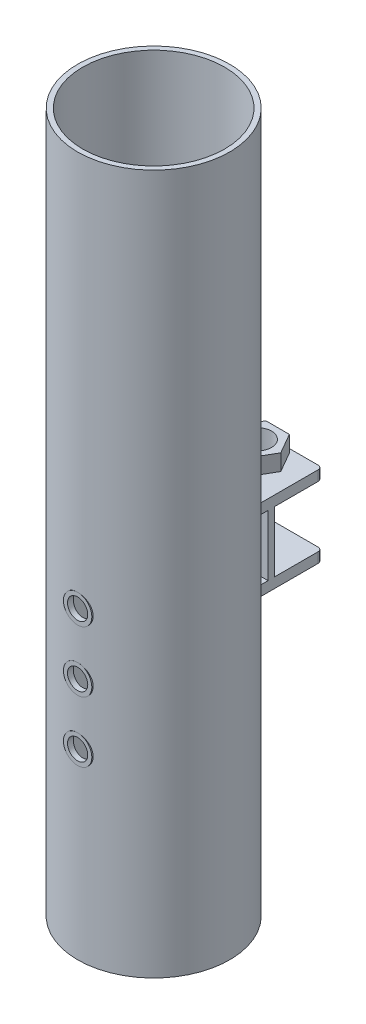
from build123d import *

# Parameters (mm, degrees)
SKETCH1_R                  = 37.5
SKETCH1_R_2                = 35
BOSS_EXTRUDE1_DEPTH        = 345
SKETCH2_R                  = 35.5
SKETCH2_R_2                = 33.5
CUT_EXTRUDE1_DEPTH         = 20
SKETCH3_R                  = 5
CUT_EXTRUDE2_DEPTH         = 10
CUT_EXTRUDE2_DEPTH_BACK    = 30
SKETCH5_R                  = 7
SKETCH5_R_2                = 5
BOSS_EXTRUDE3_DEPTH        = 1
BOSS_EXTRUDE3_2_DEPTH      = 1
SKETCH6_R                  = 7
SKETCH6_R_2                = 5
BOSS_EXTRUDE5_DEPTH        = 1
BOSS_EXTRUDE7_DEPTH        = 50
BOSS_EXTRUDE7_DEPTH_BACK   = 10
BOSS_EXTRUDE7_2_DEPTH      = 50
BOSS_EXTRUDE7_2_DEPTH_BACK = 10
SKETCH13_R                 = 7
SKETCH13_W                 = 40
SKETCH13_H                 = 24.419709383
CUT_EXTRUDE7_DEPTH         = 21
SKETCH14_R                 = 35
CUT_EXTRUDE8_DEPTH         = 346.0000001
SKETCH15_R                 = 7
BOSS_EXTRUDE8_DEPTH        = 8
SKETCH16_W                 = 40
SKETCH16_H                 = 24.419709383
CUT_EXTRUDE11_DEPTH        = 97
FILLET1_R                  = 2
FILLET2_R                  = 2
BOSS_EXTRUDE12_DEPTH       = 40


with BuildPart() as part:
    # Sketch1 → Boss-Extrude1 (new body)
    with BuildSketch(Plane(origin=(0, 0, 0), x_dir=(1, 0, 0), z_dir=(0, 1, 0))):
        Circle(SKETCH1_R)
        Circle(SKETCH1_R_2, mode=Mode.SUBTRACT)
    extrude(amount=BOSS_EXTRUDE1_DEPTH)

    # Sketch2 → Cut-Extrude1 (cut)
    with BuildSketch(Plane.XZ):
        Circle(SKETCH2_R)
        Circle(SKETCH2_R_2, mode=Mode.SUBTRACT)
    extrude(amount=-CUT_EXTRUDE1_DEPTH, mode=Mode.SUBTRACT)

    # Sketch3 → Cut-Extrude2 (cut, two sides)
    with BuildSketch(Plane.XY.offset(36.5)) as cut_extrude2_sk:
        with Locations((0, 120)):
            Circle(SKETCH3_R)
        with Locations((0, 90)):
            Circle(SKETCH3_R)
        with Locations((0, 150)):
            Circle(SKETCH3_R)
    extrude(amount=CUT_EXTRUDE2_DEPTH, mode=Mode.SUBTRACT)
    extrude(cut_extrude2_sk.sketch, amount=-CUT_EXTRUDE2_DEPTH_BACK, mode=Mode.SUBTRACT)



with BuildPart() as body_2:
    # Sketch5 → Boss-Extrude3 (new body)
    with BuildSketch(Plane.XY.offset(36.5)):
        with Locations((0, 120)):
            Circle(SKETCH5_R)
        with Locations((0, 120)):
            Circle(SKETCH5_R_2, mode=Mode.SUBTRACT)
    extrude(amount=-BOSS_EXTRUDE3_DEPTH)


with BuildPart() as body_3:
    # Sketch5 → Boss-Extrude3 2 (new body)
    with BuildSketch(Plane.XY.offset(36.5)):
        with Locations((0, 90)):
            Circle(SKETCH5_R)
        with Locations((0, 90)):
            Circle(SKETCH5_R_2, mode=Mode.SUBTRACT)
    extrude(amount=-BOSS_EXTRUDE3_2_DEPTH)


with BuildPart() as part_1:
    add(part.part)

    add(body_2.part)  # Boss-Extrude5 merges body 2

    add(body_3.part)  # Boss-Extrude5 merges body 3
    # Sketch6 → Boss-Extrude5 (add)
    with BuildSketch(Plane.XY.offset(36.5)):
        with Locations((0, 120)):
            Circle(SKETCH6_R)
        with Locations((0, 120)):
            Circle(SKETCH6_R_2, mode=Mode.SUBTRACT)
        with Locations((0, 150)):
            Circle(SKETCH6_R)
        with Locations((0, 150)):
            Circle(SKETCH6_R_2, mode=Mode.SUBTRACT)
        with Locations((0, 90)):
            Circle(SKETCH6_R)
        with Locations((0, 90)):
            Circle(SKETCH6_R_2, mode=Mode.SUBTRACT)
    extrude(amount=BOSS_EXTRUDE5_DEPTH)



with BuildPart() as body_2_2:
    # Sketch12 → Boss-Extrude7 (new body, two sides)
    with BuildSketch(Plane(origin=(0, 0, -37.5), x_dir=(-1, 0, 0), z_dir=(0, 0, -1))) as boss_extrude7_sk:
        Polygon((20, 165), (0, 165), (-20, 165), (-20, 170), (20, 170), align=None)
    extrude(amount=BOSS_EXTRUDE7_DEPTH)
    extrude(boss_extrude7_sk.sketch, amount=-BOSS_EXTRUDE7_DEPTH_BACK)

    # Sketch13 → Cut-Extrude7 (cut)
    with BuildSketch(Plane(origin=(0, 170, 0), x_dir=(1, 0, 0), z_dir=(0, 1, 0))):
        with Locations((0, 51.13401188)):
            Circle(SKETCH13_R)
        with Locations((0, 75.290145309)):
            Rectangle(SKETCH13_W, SKETCH13_H)
    extrude(amount=-CUT_EXTRUDE7_DEPTH, mode=Mode.SUBTRACT)


with BuildPart() as body_3_2:
    # Sketch12 → Boss-Extrude7 2 (new body, two sides)
    with BuildSketch(Plane(origin=(0, 0, -37.5), x_dir=(-1, 0, 0), z_dir=(0, 0, -1))) as boss_extrude7_2_sk:
        Polygon((20, 135), (20, 130), (0, 130), (-20, 130), (-20, 135), align=None)
    extrude(amount=BOSS_EXTRUDE7_2_DEPTH)
    extrude(boss_extrude7_2_sk.sketch, amount=-BOSS_EXTRUDE7_2_DEPTH_BACK)


with BuildPart() as cut_extrude8_tool:
    # Sketch14 → Cut-Extrude8 (new body, through all)
    with BuildSketch(Plane(origin=(0, 345, 0), x_dir=(1, 0, 0), z_dir=(0, 1, 0))):
        Circle(SKETCH14_R)
    extrude(amount=-CUT_EXTRUDE8_DEPTH)


with BuildPart() as body_2_2_1:
    add(body_2_2.part)

    # Cut-Extrude8: cut by cut_extrude8_tool
    add(cut_extrude8_tool.part, mode=Mode.SUBTRACT)

    # Sketch15 → Boss-Extrude8 (add)
    with BuildSketch(Plane(origin=(0, 170, 0), x_dir=(1, 0, 0), z_dir=(0, 1, 0))):
        Polygon((11.547005384, 51.13401188), (5.773502692, 61.13401188), (-5.773502692, 61.13401188), (-11.547005384, 51.13401188), (-5.773502692, 41.13401188), (5.773502692, 41.13401188), align=None)
        with Locations((0, 51.13401188)):
            Circle(SKETCH15_R, mode=Mode.SUBTRACT)
    extrude(amount=BOSS_EXTRUDE8_DEPTH)

    # Fillet1
    fillet1_edges = [body_2_2_1.edges().sort_by_distance(p)[0] for p in [
        (20, 167.5, -63.080290617),
        (-20, 167.5, -63.080290617),
    ]]
    fillet(fillet1_edges, radius=FILLET1_R)


with BuildPart() as body_3_2_1:
    add(body_3_2.part)

    # Cut-Extrude8: cut by cut_extrude8_tool
    add(cut_extrude8_tool.part, mode=Mode.SUBTRACT)

    # Sketch16 → Cut-Extrude11 (cut)
    with BuildSketch(Plane(origin=(0, 170, 0), x_dir=(1, 0, 0), z_dir=(0, 1, 0))):
        with Locations((0, 75.290145309)):
            Rectangle(SKETCH16_W, SKETCH16_H)
    extrude(amount=-CUT_EXTRUDE11_DEPTH, mode=Mode.SUBTRACT)

    # Fillet2
    fillet2_edges = [body_3_2_1.edges().sort_by_distance(p)[0] for p in [
        (20, 132.5, -63.080290617),
        (-20, 132.5, -63.080290617),
    ]]
    fillet(fillet2_edges, radius=FILLET2_R)


with BuildPart() as part_2:
    add(part_1.part)

    add(body_2_2_1.part)  # Boss-Extrude12 merges body 2 2

    add(body_3_2_1.part)  # Boss-Extrude12 merges body 3 2
    # Sketch18 → Boss-Extrude12 (add)
    with BuildSketch(Plane(origin=(20, 0, 0), x_dir=(0, 0, -1), z_dir=(1, 0, 0))):
        Polygon((39.490080652, 165), (37.410474121, 165), (36.415879692, 165), (36.415879692, 135), (39.490080652, 135), align=None)
    extrude(amount=-BOSS_EXTRUDE12_DEPTH)


solid = part_2.part
